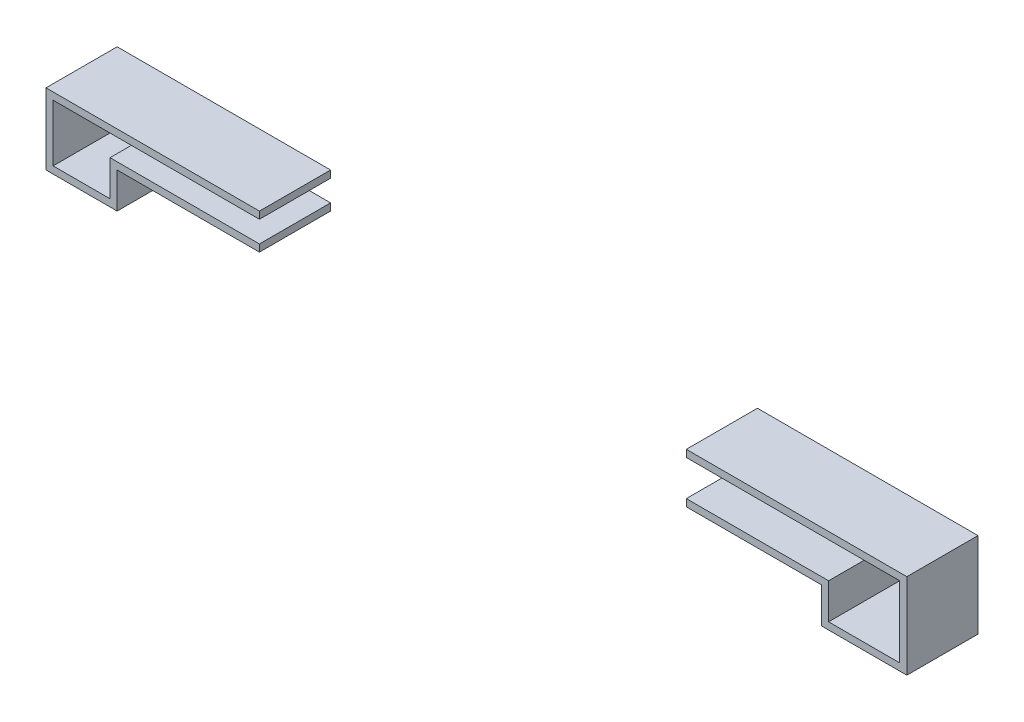
from build123d import *

# Parameters (mm, degrees)
EXTRUDE_THIN2_DEPTH   = 1
EXTRUDE_THIN2_2_DEPTH = 1


with BuildPart() as part:
    # Sketch2 → Extrude-Thin2 (new body)
    with BuildSketch(Plane.XY):
        Polygon((-3, 1), (-6, 1), (-6, 0), (-5, 0), (-5, 0.5), (-3, 0.5), (-3, 0.6), (-5.1, 0.6), (-5.1, 0.1), (-5.9, 0.1), (-5.9, 0.9), (-3, 0.9), align=None)
    extrude(amount=EXTRUDE_THIN2_DEPTH)


with BuildPart() as body_2:
    # Sketch2 → Extrude-Thin2 2 (new body)
    with BuildSketch(Plane.XY):
        Polygon((3, 1), (6, 1), (6, 0), (5, 0), (5, 0.5), (3, 0.5), (3, 0.4), (4.9, 0.4), (4.9, -0.1), (6.1, -0.1), (6.1, 1.1), (3, 1.1), align=None)
    extrude(amount=EXTRUDE_THIN2_2_DEPTH)


solid = Compound([part.part, body_2.part])
